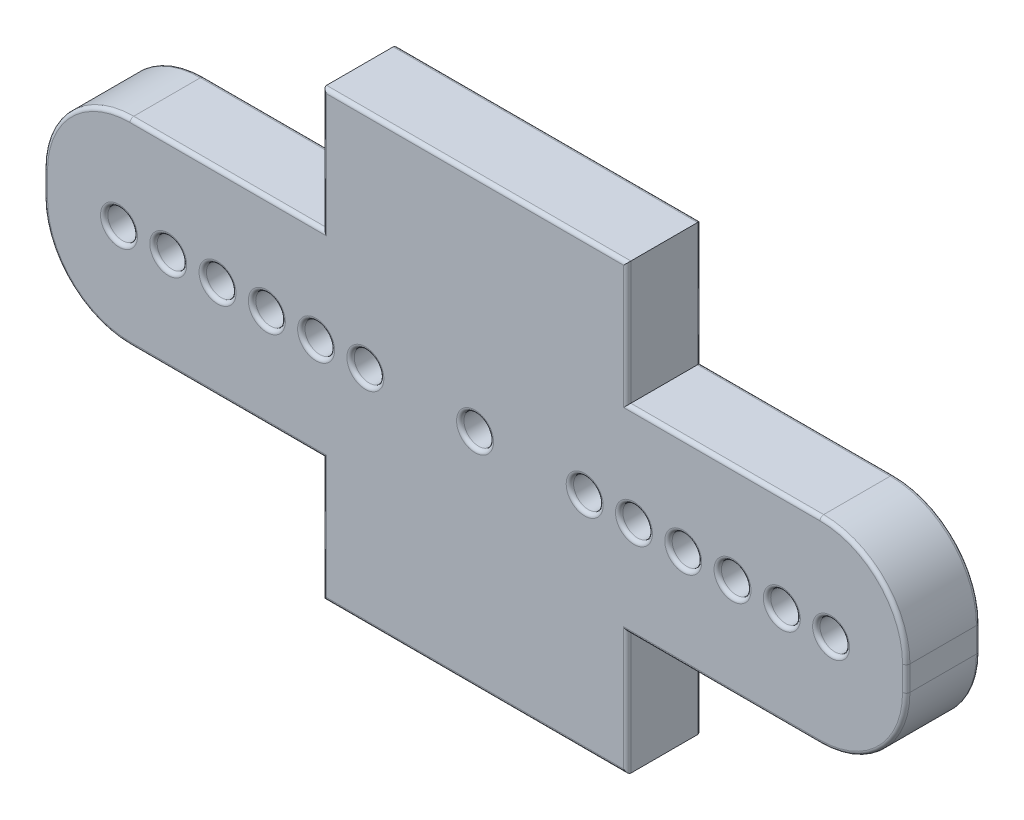
from build123d import *

# Parameters (mm, degrees)
DODANIE_WYCI_GNI_CIE1_DEPTH = 1.5
SZKIC2_R                    = 0.6
WYTNIJ_WYCI_GNI_CIE1_DEPTH  = 4
SZKIC3_R                    = 0.6
WYTNIJ_WYCI_GNI_CIE2_DEPTH  = 4
ZAOKR_GLENIE1_R             = 0.15


with BuildPart() as part:
    # Szkic1 → Dodanie-wyciągnięcie1 (new body, symmetric)
    with BuildSketch(Plane.XY):
        with BuildLine():
            Line((-17.5, -0.5), (-17.5, 0.5))
            ThreePointArc((-17.5, 0.5), (-16.474873734, 2.974873734), (-14, 4))
            Line((-14, 4), (-6.175, 4))
            Line((-6.175, 4), (-6.175, 9))
            Line((-6.175, 9), (6.175, 9))
            Line((6.175, 9), (6.175, 4))
            Line((6.175, 4), (14, 4))
            ThreePointArc((14, 4), (16.474873734, 2.974873734), (17.5, 0.5))
            Line((17.5, 0.5), (17.5, -0.5))
            ThreePointArc((17.5, -0.5), (16.474873734, -2.974873734), (14, -4))
            Line((14, -4), (6.175, -4))
            Line((6.175, -4), (6.175, -9))
            Line((6.175, -9), (-6.175, -9))
            Line((-6.175, -9), (-6.175, -4))
            Line((-6.175, -4), (-14, -4))
            ThreePointArc((-14, -4), (-16.474873734, -2.974873734), (-17.5, -0.5))
        make_face()
    extrude(amount=DODANIE_WYCI_GNI_CIE1_DEPTH, both=True)

    # Szkic2 → Wytnij-wyciągnięcie1 (cut, through all)
    with BuildSketch(Plane.XY.offset(1.5)):
        Circle(SZKIC2_R)
    extrude(amount=-WYTNIJ_WYCI_GNI_CIE1_DEPTH, mode=Mode.SUBTRACT)

    # Szkic3 → Wytnij-wyciągnięcie2 (cut, through all)
    with BuildSketch(Plane.XY.offset(1.5)):
        with Locations((-4.45, 0)):
            Circle(SZKIC3_R)
        with Locations((-6.45, 0)):
            Circle(SZKIC3_R)
        with Locations((-8.45, 0)):
            Circle(SZKIC3_R)
        with Locations((-10.45, 0)):
            Circle(SZKIC3_R)
        with Locations((-12.45, 0)):
            Circle(SZKIC3_R)
        with Locations((-14.45, 0)):
            Circle(SZKIC3_R)
    wytnij_wyci_gni_cie2 = extrude(amount=-WYTNIJ_WYCI_GNI_CIE2_DEPTH, mode=Mode.SUBTRACT)

    # Lustro1: Wytnij-wyciągnięcie2 across plane
    add(wytnij_wyci_gni_cie2.mirror(Plane(origin=(0, 0, 0), x_dir=(0, 0, 1), z_dir=(1, 0, 0))), mode=Mode.SUBTRACT)

    # Zaokrąglenie1
    zaokr_glenie1_edges = [part.edges().sort_by_distance(p)[0] for p in [
        (-6.175, 6.5, 1.5),
        (-10.0875, 4, 1.5),
        (10.0875, 4, -1.5),
        (16.474873734, 2.974873734, -1.5),
        (17.5, 0, -1.5),
        (16.474873734, -2.974873734, -1.5),
        (10.0875, -4, -1.5),
        (-16.474873734, 2.974873734, 1.5),
        (6.175, -6.5, -1.5),
        (0, -9, -1.5),
        (-6.175, -6.5, -1.5),
        (-10.0875, -4, -1.5),
        (-16.474873734, -2.974873734, -1.5),
        (-17.5, 0, -1.5),
        (-16.474873734, 2.974873734, -1.5),
        (-10.0875, 4, -1.5),
        (-17.5, 0, 1.5),
        (-6.175, 6.5, -1.5),
        (0, 9, -1.5),
        (6.175, 6.5, -1.5),
        (-16.474873734, -2.974873734, 1.5),
        (-10.0875, -4, 1.5),
        (-6.175, -6.5, 1.5),
        (0, -9, 1.5),
        (6.175, -6.5, 1.5),
        (10.0875, -4, 1.5),
        (6.175, 6.5, 1.5),
        (16.474873734, -2.974873734, 1.5),
        (17.5, 0, 1.5),
        (16.474873734, 2.974873734, 1.5),
        (-0.6, 0, -1.5),
        (-0.6, 0, 1.5),
        (10.0875, 4, 1.5),
        (-5.05, 0, -1.5),
        (-5.05, 0, 1.5),
        (-7.05, 0, -1.5),
        (-7.05, 0, 1.5),
        (-9.05, 0, -1.5),
        (-9.05, 0, 1.5),
        (-11.05, 0, -1.5),
        (-11.05, 0, 1.5),
        (-13.05, 0, -1.5),
        (-13.05, 0, 1.5),
        (-15.05, 0, -1.5),
        (-15.05, 0, 1.5),
        (0, 9, 1.5),
        (5.05, 0, 1.5),
        (5.05, 0, -1.5),
        (7.05, 0, 1.5),
        (7.05, 0, -1.5),
        (9.05, 0, 1.5),
        (9.05, 0, -1.5),
        (11.05, 0, 1.5),
        (11.05, 0, -1.5),
        (13.05, 0, 1.5),
        (13.05, 0, -1.5),
        (15.05, 0, 1.5),
        (15.05, 0, -1.5),
    ]]
    fillet(zaokr_glenie1_edges, radius=ZAOKR_GLENIE1_R)


solid = part.part
